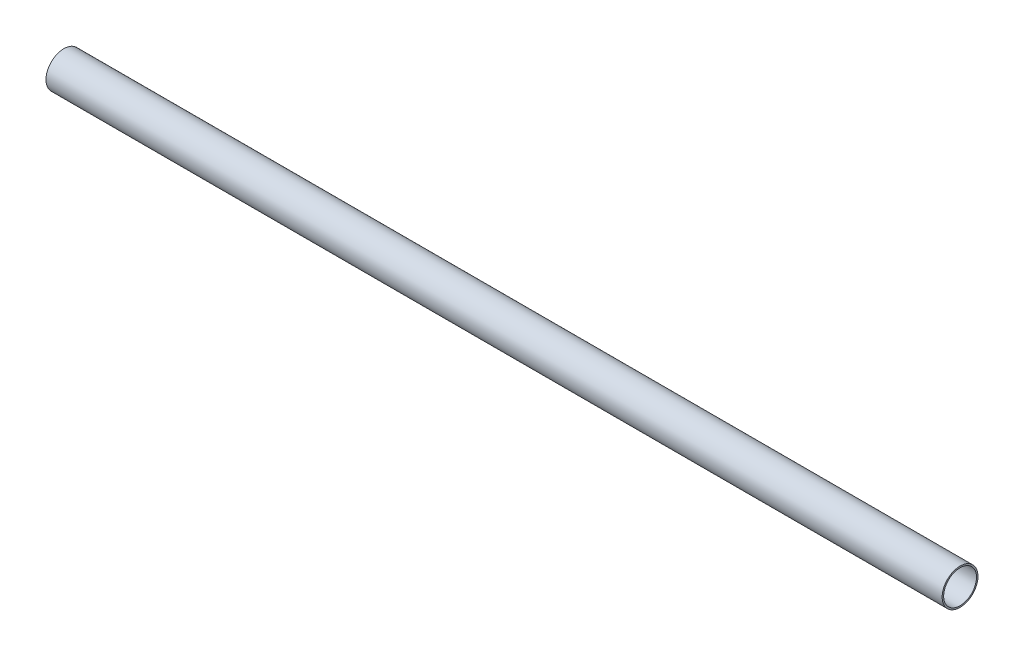
from build123d import *

# Parameters (mm, degrees)
SKETCH_1_W = 300
SKETCH_1_H = 0.5


with BuildPart() as part:
    # 草图1 → 旋转1 (revolve)
    with BuildSketch(Plane.XY):
        with Locations((-300, 5.711)):
            Rectangle(SKETCH_1_W, SKETCH_1_H)
    revolve(axis=Axis((-450, -0.039, 0), (1, 0, 0)))


solid = part.part
